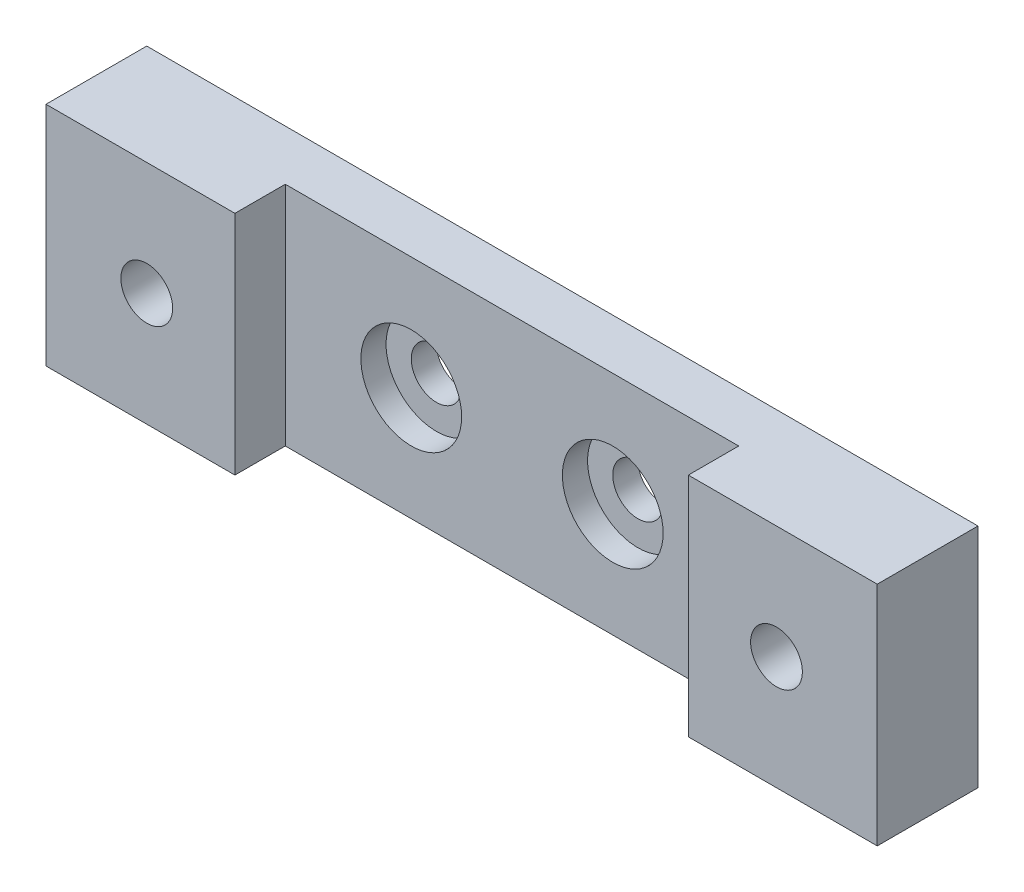
from build123d import *

# Parameters (mm, degrees)
BOSS_EXTRUDE1_DEPTH      = 28.575
HOLE1_D                  = 6.35
HOLE1_DEPTH              = 6.35
HOLE1_CBORE_D            = 12.7
HOLE1_CBORE_DEPTH        = 3.175
HOLE1_TIP                = 1.907732465
F_5_16_18_TAPPED_HOLE1_D = 6.5278


with BuildPart() as part:
    # Sketch1 → Boss-Extrude1 (new body)
    with BuildSketch(Plane(origin=(0, 0, 0), x_dir=(1, 0, 0), z_dir=(0, 1, 0))):
        Polygon((-52.3875, 0), (52.3875, 0), (52.3875, -12.7), (28.575, -12.7), (28.575, -6.35), (-28.575, -6.35), (-28.575, -12.7), (-52.3875, -12.7), align=None)
    extrude(amount=BOSS_EXTRUDE1_DEPTH)

    # Hole1
    with Locations(Plane(origin=(0, 0, 6.35), x_dir=(-1, 0, 0), z_dir=(0, 0, 1))):
        with Locations((-12.7, -14.2875), (12.7, -14.2875)):
            CounterBoreHole(HOLE1_D / 2, HOLE1_CBORE_D / 2, HOLE1_CBORE_DEPTH, depth=HOLE1_DEPTH)
            with Locations((0, 0, -(HOLE1_DEPTH + HOLE1_TIP / 2))):  # 118° drill point
                Cone(0, HOLE1_D / 2, HOLE1_TIP, mode=Mode.SUBTRACT)

    # 5/16-18 Tapped Hole1 (through all)
    with Locations(Plane.XY.offset(12.7)):
        with Locations((-39.6875, 14.2875), (39.6875, 14.2875)):
            Hole(F_5_16_18_TAPPED_HOLE1_D / 2)


solid = part.part
